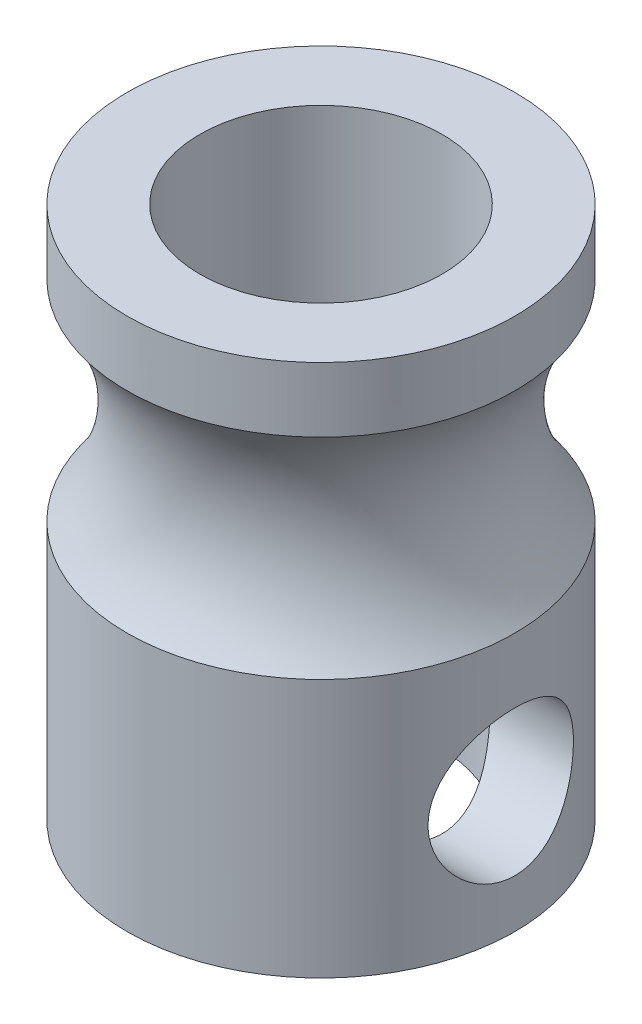
from build123d import *

# Parameters (mm, degrees)
CROQUIS1_R              = 4
CROQUIS1_R_2            = 2.5
SALIENTE_EXTRUIR1_DEPTH = 11
CROQUIS2_R              = 1.5
CORTAR_EXTRUIR2_DEPTH   = 2
CROQUIS3_R              = 3.5
CROQUIS3_R_2            = 3


with BuildPart() as part:
    # Croquis1 → Saliente-Extruir1 (new body)
    with BuildSketch(Plane(origin=(0, 0, 0), x_dir=(1, 0, 0), z_dir=(0, 1, 0))):
        Circle(CROQUIS1_R)
        Circle(CROQUIS1_R_2, mode=Mode.SUBTRACT)
    extrude(amount=SALIENTE_EXTRUIR1_DEPTH)

    # Croquis2 → Cortar-Extruir2 (cut)
    with BuildSketch(Plane(origin=(4, 0, 0), x_dir=(0, 0, -1), z_dir=(1, 0, 0))):
        with Locations((0, 2.5)):
            Circle(CROQUIS2_R)
    extrude(amount=-CORTAR_EXTRUIR2_DEPTH, mode=Mode.SUBTRACT)

    # Croquis3 → Cortar-Revolución2 (revolve, cut)
    with BuildSketch(Plane.XY):
        with Locations((6.75, 7.5)):
            Circle(CROQUIS3_R)
        with Locations((-6.75, 7.5)):
            Circle(CROQUIS3_R_2)
    revolve(axis=Axis((0, 0, 0), (0, 1, 0)), mode=Mode.SUBTRACT)


solid = part.part
